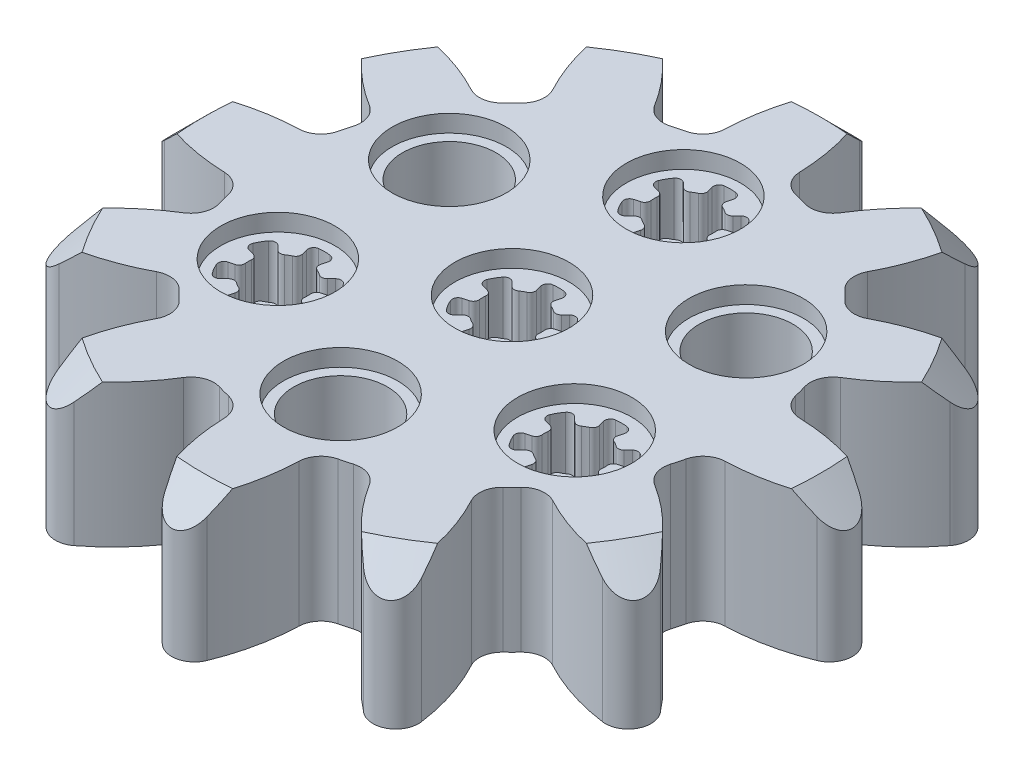
from build123d import *

# Parameters (mm, degrees)
SKETCH3_R           = 32
BOSS_EXTRUDE1_DEPTH = 12.5
CHAMFER1_SIZE       = 5
CUT_EXTRUDE3_DEPTH  = 47.949440891
SKETCH7_R           = 4.1
CUT_EXTRUDE4_DEPTH  = 47.949441054
SKETCH7_7_R         = 5
SKETCH7_7_R_2       = 4.1
CUT_EXTRUDE5_DEPTH  = 1.5
CUT_EXTRUDE8_DEPTH  = 9
SKETCH10_R          = 5
SKETCH10_R_2        = 4.1
BOSS_EXTRUDE2_DEPTH = 5
FILLET2_R           = 0.5
FILLET5_R           = 2
SKETCH8_R           = 1
CUT_EXTRUDE6_DEPTH  = 46.611126858


with BuildPart() as part:
    # Sketch3 → Boss-Extrude1 (new body)
    with BuildSketch(Plane(origin=(0, 0, 0), x_dir=(1, 0, 0), z_dir=(0, 1, 0))):
        with Locations(Location((0, 0, 0), (0, 0, 270))):
            Circle(SKETCH3_R)
    extrude(amount=BOSS_EXTRUDE1_DEPTH)

    # Chamfer1
    chamfer1_edges = [part.edges().sort_by_distance(p)[0] for p in [
        (0, 12.5, -32),
    ]]
    chamfer(chamfer1_edges, length=CHAMFER1_SIZE)

    # Sketch5 → Cut-Extrude3 (cut, through all)
    with BuildSketch(Plane(origin=(0, 12.5, 0), x_dir=(1, 0, 0), z_dir=(0, 1, 0))):
        with BuildLine():
            ThreePointArc((0.281278544, -31.998763763), (0.282056068, -31.998756919), (0.282833592, -31.998750056))
            ThreePointArc((0.282833592, -31.998750056), (8.418728035, -30.872722884), (16, -27.712812921))
            ThreePointArc((16, -27.712812921), (10.989548885, -24.179940154), (7.356424025, -19.241700173))
            ThreePointArc((7.356424025, -19.241700173), (5.331672329, -19.898072022), (3.25, -20.342013175))
            ThreePointArc((3.25, -20.342013175), (2.572741567, -26.435216878), (0, -32))
            ThreePointArc((0, -32), (0.14064063, -31.999690939), (0.281278544, -31.998763763))
        make_face()
        with BuildLine():
            ThreePointArc((12.98558915, -15.991700173), (15.445667993, -21.607198588), (16, -27.712812921))
            ThreePointArc((16, -27.712812921), (22.627416998, -22.627416998), (27.712812921, -16))
            ThreePointArc((27.712812921, -16), (21.607198588, -15.445667993), (15.991700173, -12.98558915))
            ThreePointArc((15.991700173, -12.98558915), (14.566399692, -14.566399692), (12.98558915, -15.991700173))
        make_face()
        with BuildLine():
            ThreePointArc((-16, -27.712812921), (-8.282209443, -30.909626441), (0, -32))
            ThreePointArc((0, -32), (-2.572741567, -26.435216878), (-3.25, -20.342013175))
            ThreePointArc((-3.25, -20.342013175), (-5.331672329, -19.898072022), (-7.356424025, -19.241700173))
            ThreePointArc((-7.356424025, -19.241700173), (-10.989548885, -24.179940154), (-16, -27.712812921))
        make_face()
        with BuildLine():
            ThreePointArc((19.241700173, -7.356424025), (24.179940154, -10.989548885), (27.712812921, -16))
            ThreePointArc((27.712812921, -16), (30.909626441, -8.282209443), (32, 0))
            ThreePointArc((32, 0), (26.435216878, -2.572741567), (20.342013175, -3.25))
            ThreePointArc((20.342013175, -3.25), (19.898072022, -5.331672329), (19.241700173, -7.356424025))
        make_face()
        with BuildLine():
            ThreePointArc((-27.712812921, -16), (-22.627416998, -22.627416998), (-16, -27.712812921))
            ThreePointArc((-16, -27.712812921), (-15.445667993, -21.607198588), (-12.98558915, -15.991700173))
            ThreePointArc((-12.98558915, -15.991700173), (-14.566399692, -14.566399692), (-15.991700173, -12.98558915))
            ThreePointArc((-15.991700173, -12.98558915), (-21.607198588, -15.445667993), (-27.712812921, -16))
        make_face()
        with BuildLine():
            ThreePointArc((20.342013175, 3.25), (26.435216878, 2.572741567), (32, 0))
            ThreePointArc((32, 0), (30.909626441, 8.282209443), (27.712812921, 16))
            ThreePointArc((27.712812921, 16), (24.179940154, 10.989548885), (19.241700173, 7.356424025))
            ThreePointArc((19.241700173, 7.356424025), (19.898072022, 5.331672329), (20.342013175, 3.25))
        make_face()
        with BuildLine():
            ThreePointArc((-32, 0), (-30.909626441, -8.282209443), (-27.712812921, -16))
            ThreePointArc((-27.712812921, -16), (-24.179940154, -10.989548885), (-19.241700173, -7.356424025))
            ThreePointArc((-19.241700173, -7.356424025), (-19.898072022, -5.331672329), (-20.342013175, -3.25))
            ThreePointArc((-20.342013175, -3.25), (-26.435216878, -2.572741567), (-32, 0))
        make_face()
        with BuildLine():
            ThreePointArc((15.991700173, 12.98558915), (21.607198588, 15.445667993), (27.712812921, 16))
            ThreePointArc((27.712812921, 16), (22.627416998, 22.627416998), (16, 27.712812921))
            ThreePointArc((16, 27.712812921), (15.445667993, 21.607198588), (12.98558915, 15.991700173))
            ThreePointArc((12.98558915, 15.991700173), (14.566399692, 14.566399692), (15.991700173, 12.98558915))
        make_face()
        with BuildLine():
            ThreePointArc((-27.712812921, 16), (-30.909626441, 8.282209443), (-32, 0))
            ThreePointArc((-32, 0), (-26.435216878, 2.572741567), (-20.342013175, 3.25))
            ThreePointArc((-20.342013175, 3.25), (-19.898072022, 5.331672329), (-19.241700173, 7.356424025))
            ThreePointArc((-19.241700173, 7.356424025), (-24.179940154, 10.989548885), (-27.712812921, 16))
        make_face()
        with BuildLine():
            ThreePointArc((7.356424025, 19.241700173), (10.989548885, 24.179940154), (16, 27.712812921))
            ThreePointArc((16, 27.712812921), (8.282209443, 30.909626441), (0, 32))
            ThreePointArc((0, 32), (2.572741567, 26.435216878), (3.25, 20.342013175))
            ThreePointArc((3.25, 20.342013175), (5.331672329, 19.898072022), (7.356424025, 19.241700173))
        make_face()
        with BuildLine():
            ThreePointArc((-16, 27.712812921), (-22.627416998, 22.627416998), (-27.712812921, 16))
            ThreePointArc((-27.712812921, 16), (-21.607198588, 15.445667993), (-15.991700173, 12.98558915))
            ThreePointArc((-15.991700173, 12.98558915), (-14.566399692, 14.566399692), (-12.98558915, 15.991700173))
            ThreePointArc((-12.98558915, 15.991700173), (-15.445667993, 21.607198588), (-16, 27.712812921))
        make_face()
        with BuildLine():
            ThreePointArc((-3.25, 20.342013175), (-2.572741567, 26.435216878), (0, 32))
            ThreePointArc((0, 32), (-8.282209443, 30.909626441), (-16, 27.712812921))
            ThreePointArc((-16, 27.712812921), (-10.989548885, 24.179940154), (-7.356424025, 19.241700173))
            ThreePointArc((-7.356424025, 19.241700173), (-5.331672329, 19.898072022), (-3.25, 20.342013175))
        make_face()
    extrude(amount=-CUT_EXTRUDE3_DEPTH, mode=Mode.SUBTRACT)

    # Sketch7 → Cut-Extrude4 (cut, through all)
    with BuildSketch(Plane(origin=(0, 12.5, 0), x_dir=(1, 0, 0), z_dir=(0, 1, 0))):
        with BuildLine():
            ThreePointArc((1.838477631, 16.838477631), (1.3, 17.25166605), (0.672929517, 17.511407148))
            Line((0.672929517, 17.511407148), (1.061158085, 18.960295888))
            ThreePointArc((1.061158085, 18.960295888), (0, 19.1), (-1.061158085, 18.960295888))
            Line((-1.061158085, 18.960295888), (-0.672929517, 17.511407148))
            ThreePointArc((-0.672929517, 17.511407148), (-1.3, 17.25166605), (-1.838477631, 16.838477631))
            Line((-1.838477631, 16.838477631), (-2.899137803, 17.899137803))
            ThreePointArc((-2.899137803, 17.899137803), (-3.550704156, 17.05), (-3.960295888, 16.061158085))
            Line((-3.960295888, 16.061158085), (-2.511407148, 15.672929517))
            ThreePointArc((-2.511407148, 15.672929517), (-2.6, 15), (-2.511407148, 14.327070483))
            Line((-2.511407148, 14.327070483), (-3.960295888, 13.938841915))
            ThreePointArc((-3.960295888, 13.938841915), (-3.550704156, 12.95), (-2.899137803, 12.100862197))
            Line((-2.899137803, 12.100862197), (-1.838477631, 13.161522369))
            ThreePointArc((-1.838477631, 13.161522369), (-1.3, 12.74833395), (-0.672929517, 12.488592852))
            Line((-0.672929517, 12.488592852), (-1.061158085, 11.039704112))
            ThreePointArc((-1.061158085, 11.039704112), (0, 10.9), (1.061158085, 11.039704112))
            Line((1.061158085, 11.039704112), (0.672929517, 12.488592852))
            ThreePointArc((0.672929517, 12.488592852), (1.3, 12.74833395), (1.838477631, 13.161522369))
            Line((1.838477631, 13.161522369), (2.899137803, 12.100862197))
            ThreePointArc((2.899137803, 12.100862197), (3.550704156, 12.95), (3.960295888, 13.938841915))
            Line((3.960295888, 13.938841915), (2.511407148, 14.327070483))
            ThreePointArc((2.511407148, 14.327070483), (2.6, 15), (2.511407148, 15.672929517))
            Line((2.511407148, 15.672929517), (3.960295888, 16.061158085))
            ThreePointArc((3.960295888, 16.061158085), (3.550704156, 17.05), (2.899137803, 17.899137803))
            Line((2.899137803, 17.899137803), (1.838477631, 16.838477631))
        make_face()
        with Locations(Location((12.990381057, 7.5, 0), (0, 0, 270))):
            Circle(SKETCH7_R)
        with BuildLine():
            Line((1.061158085, -3.960295888), (0.672929517, -2.511407148))
            ThreePointArc((0.672929517, -2.511407148), (1.3, -2.25166605), (1.838477631, -1.838477631))
            Line((1.838477631, -1.838477631), (2.899137803, -2.899137803))
            ThreePointArc((2.899137803, -2.899137803), (3.550704156, -2.05), (3.960295888, -1.061158085))
            Line((3.960295888, -1.061158085), (2.511407148, -0.672929517))
            ThreePointArc((2.511407148, -0.672929517), (2.6, 0), (2.511407148, 0.672929517))
            Line((2.511407148, 0.672929517), (3.960295888, 1.061158085))
            ThreePointArc((3.960295888, 1.061158085), (3.550704156, 2.05), (2.899137803, 2.899137803))
            Line((2.899137803, 2.899137803), (1.838477631, 1.838477631))
            ThreePointArc((1.838477631, 1.838477631), (1.3, 2.25166605), (0.672929517, 2.511407148))
            Line((0.672929517, 2.511407148), (1.061158085, 3.960295888))
            ThreePointArc((1.061158085, 3.960295888), (0, 4.1), (-1.061158085, 3.960295888))
            Line((-1.061158085, 3.960295888), (-0.672929517, 2.511407148))
            ThreePointArc((-0.672929517, 2.511407148), (-1.3, 2.25166605), (-1.838477631, 1.838477631))
            Line((-1.838477631, 1.838477631), (-2.899137803, 2.899137803))
            ThreePointArc((-2.899137803, 2.899137803), (-3.550704156, 2.05), (-3.960295888, 1.061158085))
            Line((-3.960295888, 1.061158085), (-2.511407148, 0.672929517))
            ThreePointArc((-2.511407148, 0.672929517), (-2.6, 0), (-2.511407148, -0.672929517))
            Line((-2.511407148, -0.672929517), (-3.960295888, -1.061158085))
            ThreePointArc((-3.960295888, -1.061158085), (-3.550704156, -2.05), (-2.899137803, -2.899137803))
            Line((-2.899137803, -2.899137803), (-1.838477631, -1.838477631))
            ThreePointArc((-1.838477631, -1.838477631), (-1.3, -2.25166605), (-0.672929517, -2.511407148))
            Line((-0.672929517, -2.511407148), (-1.061158085, -3.960295888))
            ThreePointArc((-1.061158085, -3.960295888), (0, -4.1), (1.061158085, -3.960295888))
        make_face()
        with Locations(Location((-12.990381057, 7.5, 0), (0, 0, 270))):
            Circle(SKETCH7_R)
        with BuildLine():
            ThreePointArc((-14.828858688, -9.338477631), (-14.290381057, -9.75166605), (-13.663310574, -10.011407148))
            Line((-13.663310574, -10.011407148), (-14.051539142, -11.460295888))
            ThreePointArc((-14.051539142, -11.460295888), (-12.990381057, -11.6), (-11.929222972, -11.460295888))
            Line((-11.929222972, -11.460295888), (-12.317451539, -10.011407148))
            ThreePointArc((-12.317451539, -10.011407148), (-11.690381057, -9.75166605), (-11.151903426, -9.338477631))
            Line((-11.151903426, -9.338477631), (-10.091243254, -10.399137803))
            ThreePointArc((-10.091243254, -10.399137803), (-9.439676901, -9.55), (-9.030085169, -8.561158085))
            Line((-9.030085169, -8.561158085), (-10.478973908, -8.172929517))
            ThreePointArc((-10.478973908, -8.172929517), (-10.390381057, -7.5), (-10.478973908, -6.827070483))
            Line((-10.478973908, -6.827070483), (-9.030085169, -6.438841915))
            ThreePointArc((-9.030085169, -6.438841915), (-9.439676901, -5.45), (-10.091243254, -4.600862197))
            Line((-10.091243254, -4.600862197), (-11.151903426, -5.661522369))
            ThreePointArc((-11.151903426, -5.661522369), (-11.690381057, -5.24833395), (-12.317451539, -4.988592852))
            Line((-12.317451539, -4.988592852), (-11.929222972, -3.539704112))
            ThreePointArc((-11.929222972, -3.539704112), (-12.990381057, -3.4), (-14.051539142, -3.539704112))
            Line((-14.051539142, -3.539704112), (-13.663310574, -4.988592852))
            ThreePointArc((-13.663310574, -4.988592852), (-14.290381057, -5.24833395), (-14.828858688, -5.661522369))
            Line((-14.828858688, -5.661522369), (-15.88951886, -4.600862197))
            ThreePointArc((-15.88951886, -4.600862197), (-16.541085212, -5.45), (-16.950676945, -6.438841915))
            Line((-16.950676945, -6.438841915), (-15.501788205, -6.827070483))
            ThreePointArc((-15.501788205, -6.827070483), (-15.590381057, -7.5), (-15.501788205, -8.172929517))
            Line((-15.501788205, -8.172929517), (-16.950676945, -8.561158085))
            ThreePointArc((-16.950676945, -8.561158085), (-16.541085212, -9.55), (-15.88951886, -10.399137803))
            Line((-15.88951886, -10.399137803), (-14.828858688, -9.338477631))
        make_face()
        with Locations(Location((0, -15, 0), (0, 0, 270))):
            Circle(SKETCH7_R)
        with BuildLine():
            ThreePointArc((15.501788205, -8.172929517), (15.590381057, -7.5), (15.501788205, -6.827070483))
            Line((15.501788205, -6.827070483), (16.950676945, -6.438841915))
            ThreePointArc((16.950676945, -6.438841915), (16.541085212, -5.45), (15.88951886, -4.600862197))
            Line((15.88951886, -4.600862197), (14.828858688, -5.661522369))
            ThreePointArc((14.828858688, -5.661522369), (14.290381057, -5.24833395), (13.663310574, -4.988592852))
            Line((13.663310574, -4.988592852), (14.051539142, -3.539704112))
            ThreePointArc((14.051539142, -3.539704112), (12.990381057, -3.4), (11.929222972, -3.539704112))
            Line((11.929222972, -3.539704112), (12.31745154, -4.988592852))
            ThreePointArc((12.31745154, -4.988592852), (11.690381057, -5.24833395), (11.151903426, -5.661522369))
            Line((11.151903426, -5.661522369), (10.091243254, -4.600862197))
            ThreePointArc((10.091243254, -4.600862197), (9.439676901, -5.45), (9.030085169, -6.438841915))
            Line((9.030085169, -6.438841915), (10.478973908, -6.827070483))
            ThreePointArc((10.478973908, -6.827070483), (10.390381057, -7.5), (10.478973908, -8.172929517))
            Line((10.478973908, -8.172929517), (9.030085169, -8.561158085))
            ThreePointArc((9.030085169, -8.561158085), (9.439676901, -9.55), (10.091243254, -10.399137803))
            Line((10.091243254, -10.399137803), (11.151903426, -9.338477631))
            ThreePointArc((11.151903426, -9.338477631), (11.690381057, -9.75166605), (12.31745154, -10.011407148))
            Line((12.31745154, -10.011407148), (11.929222972, -11.460295888))
            ThreePointArc((11.929222972, -11.460295888), (12.990381057, -11.6), (14.051539142, -11.460295888))
            Line((14.051539142, -11.460295888), (13.663310574, -10.011407148))
            ThreePointArc((13.663310574, -10.011407148), (14.290381057, -9.75166605), (14.828858688, -9.338477631))
            Line((14.828858688, -9.338477631), (15.88951886, -10.399137803))
            ThreePointArc((15.88951886, -10.399137803), (16.541085212, -9.55), (16.950676945, -8.561158085))
            Line((16.950676945, -8.561158085), (15.501788205, -8.172929517))
        make_face()
    extrude(amount=-CUT_EXTRUDE4_DEPTH, mode=Mode.SUBTRACT)

    # Sketch7_7 → Cut-Extrude5 (cut)
    with BuildSketch(Plane(origin=(0, 12.5, 0), x_dir=(1, 0, 0), z_dir=(0, 1, 0))):
        with Locations(Location((-12.990381057, 7.5, 0), (0, 0, 270))):
            Circle(SKETCH7_7_R)
        with Locations(Location((-12.990381057, 7.5, 0), (0, 0, 270))):
            Circle(SKETCH7_7_R_2, mode=Mode.SUBTRACT)
        with Locations(Location((12.990381057, 7.5, 0), (0, 0, 270))):
            Circle(SKETCH7_7_R)
        with Locations(Location((12.990381057, 7.5, 0), (0, 0, 270))):
            Circle(SKETCH7_7_R_2, mode=Mode.SUBTRACT)
        with Locations(Location((0, 15, 0), (0, 0, 270))):
            Circle(SKETCH7_7_R)
        with Locations((0, 15)):
            Circle(SKETCH7_7_R_2, mode=Mode.SUBTRACT)
        with BuildLine():
            Line((-2.511407148, 15.672929517), (-3.960295888, 16.061158085))
            ThreePointArc((-3.960295888, 16.061158085), (-4.1, 15), (-3.960295888, 13.938841915))
            Line((-3.960295888, 13.938841915), (-2.511407148, 14.327070483))
            ThreePointArc((-2.511407148, 14.327070483), (-2.6, 15), (-2.511407148, 15.672929517))
        make_face()
        with BuildLine():
            Line((-1.838477631, 13.161522369), (-2.899137803, 12.100862197))
            ThreePointArc((-2.899137803, 12.100862197), (-2.05, 11.449295844), (-1.061158085, 11.039704112))
            Line((-1.061158085, 11.039704112), (-0.672929517, 12.488592852))
            ThreePointArc((-0.672929517, 12.488592852), (-1.3, 12.74833395), (-1.838477631, 13.161522369))
        make_face()
        with BuildLine():
            ThreePointArc((1.061158085, 11.039704112), (2.05, 11.449295844), (2.899137803, 12.100862197))
            Line((2.899137803, 12.100862197), (1.838477631, 13.161522369))
            ThreePointArc((1.838477631, 13.161522369), (1.3, 12.74833395), (0.672929517, 12.488592852))
            Line((0.672929517, 12.488592852), (1.061158085, 11.039704112))
        make_face()
        with BuildLine():
            ThreePointArc((4.1, 15), (4.064923932, 15.535157388), (3.960295888, 16.061158085))
            Line((3.960295888, 16.061158085), (2.511407148, 15.672929517))
            ThreePointArc((2.511407148, 15.672929517), (2.6, 15), (2.511407148, 14.327070483))
            Line((2.511407148, 14.327070483), (3.960295888, 13.938841915))
            ThreePointArc((3.960295888, 13.938841915), (4.064923932, 14.464842612), (4.1, 15))
        make_face()
        with BuildLine():
            Line((1.061158085, 18.960295888), (0.672929517, 17.511407148))
            ThreePointArc((0.672929517, 17.511407148), (1.3, 17.25166605), (1.838477631, 16.838477631))
            Line((1.838477631, 16.838477631), (2.899137803, 17.899137803))
            ThreePointArc((2.899137803, 17.899137803), (2.05, 18.550704156), (1.061158085, 18.960295888))
        make_face()
        with BuildLine():
            Line((-0.672929517, 17.511407148), (-1.061158085, 18.960295888))
            ThreePointArc((-1.061158085, 18.960295888), (-2.05, 18.550704156), (-2.899137803, 17.899137803))
            Line((-2.899137803, 17.899137803), (-1.838477631, 16.838477631))
            ThreePointArc((-1.838477631, 16.838477631), (-1.3, 17.25166605), (-0.672929517, 17.511407148))
        make_face()
        with Locations(Location((0, 0, 0), (0, 0, 270))):
            Circle(SKETCH7_7_R)
        Circle(SKETCH7_7_R_2, mode=Mode.SUBTRACT)
        with Locations(Location((-12.990381057, -7.5, 0), (0, 0, 270))):
            Circle(SKETCH7_7_R)
        with Locations((-12.990381057, -7.5)):
            Circle(SKETCH7_7_R_2, mode=Mode.SUBTRACT)
        with BuildLine():
            ThreePointArc((-16.950676945, -6.438841915), (-17.090381057, -7.5), (-16.950676945, -8.561158085))
            Line((-16.950676945, -8.561158085), (-15.501788205, -8.172929517))
            ThreePointArc((-15.501788205, -8.172929517), (-15.590381057, -7.5), (-15.501788205, -6.827070483))
            Line((-15.501788205, -6.827070483), (-16.950676945, -6.438841915))
        make_face()
        with BuildLine():
            Line((2.511407148, -0.672929517), (3.960295888, -1.061158085))
            ThreePointArc((3.960295888, -1.061158085), (4.064923932, -0.535157388), (4.1, 0))
            ThreePointArc((4.1, 0), (4.064923932, 0.535157388), (3.960295888, 1.061158085))
            Line((3.960295888, 1.061158085), (2.511407148, 0.672929517))
            ThreePointArc((2.511407148, 0.672929517), (2.6, 0), (2.511407148, -0.672929517))
        make_face()
        with BuildLine():
            Line((1.838477631, 1.838477631), (2.899137803, 2.899137803))
            ThreePointArc((2.899137803, 2.899137803), (2.05, 3.550704156), (1.061158085, 3.960295888))
            Line((1.061158085, 3.960295888), (0.672929517, 2.511407148))
            ThreePointArc((0.672929517, 2.511407148), (1.3, 2.25166605), (1.838477631, 1.838477631))
        make_face()
        with BuildLine():
            ThreePointArc((-1.061158085, 3.960295888), (-2.05, 3.550704156), (-2.899137803, 2.899137803))
            Line((-2.899137803, 2.899137803), (-1.838477631, 1.838477631))
            ThreePointArc((-1.838477631, 1.838477631), (-1.3, 2.25166605), (-0.672929517, 2.511407148))
            Line((-0.672929517, 2.511407148), (-1.061158085, 3.960295888))
        make_face()
        with BuildLine():
            ThreePointArc((-3.960295888, 1.061158085), (-4.1, 0), (-3.960295888, -1.061158085))
            Line((-3.960295888, -1.061158085), (-2.511407148, -0.672929517))
            ThreePointArc((-2.511407148, -0.672929517), (-2.6, 0), (-2.511407148, 0.672929517))
            Line((-2.511407148, 0.672929517), (-3.960295888, 1.061158085))
        make_face()
        with BuildLine():
            ThreePointArc((-2.899137803, -2.899137803), (-2.05, -3.550704156), (-1.061158085, -3.960295888))
            Line((-1.061158085, -3.960295888), (-0.672929517, -2.511407148))
            ThreePointArc((-0.672929517, -2.511407148), (-1.3, -2.25166605), (-1.838477631, -1.838477631))
            Line((-1.838477631, -1.838477631), (-2.899137803, -2.899137803))
        make_face()
        with BuildLine():
            ThreePointArc((1.838477631, -1.838477631), (1.3, -2.25166605), (0.672929517, -2.511407148))
            Line((0.672929517, -2.511407148), (1.061158085, -3.960295888))
            ThreePointArc((1.061158085, -3.960295888), (2.05, -3.550704156), (2.899137803, -2.899137803))
            Line((2.899137803, -2.899137803), (1.838477631, -1.838477631))
        make_face()
        with Locations(Location((12.990381057, -7.5, 0), (0, 0, 270))):
            Circle(SKETCH7_7_R)
        with Locations((12.990381057, -7.5)):
            Circle(SKETCH7_7_R_2, mode=Mode.SUBTRACT)
        with BuildLine():
            Line((10.478973908, -6.827070483), (9.030085169, -6.438841915))
            ThreePointArc((9.030085169, -6.438841915), (8.890381057, -7.5), (9.030085169, -8.561158085))
            Line((9.030085169, -8.561158085), (10.478973908, -8.172929517))
            ThreePointArc((10.478973908, -8.172929517), (10.390381057, -7.5), (10.478973908, -6.827070483))
        make_face()
        with BuildLine():
            ThreePointArc((10.091243254, -10.399137803), (10.940381057, -11.050704156), (11.929222972, -11.460295888))
            Line((11.929222972, -11.460295888), (12.31745154, -10.011407148))
            ThreePointArc((12.31745154, -10.011407148), (11.690381057, -9.75166605), (11.151903426, -9.338477631))
            Line((11.151903426, -9.338477631), (10.091243254, -10.399137803))
        make_face()
        with BuildLine():
            ThreePointArc((14.051539142, -11.460295888), (15.040381057, -11.050704156), (15.88951886, -10.399137803))
            Line((15.88951886, -10.399137803), (14.828858688, -9.338477631))
            ThreePointArc((14.828858688, -9.338477631), (14.290381057, -9.75166605), (13.663310574, -10.011407148))
            Line((13.663310574, -10.011407148), (14.051539142, -11.460295888))
        make_face()
        with BuildLine():
            Line((16.950676945, -6.438841915), (15.501788205, -6.827070483))
            ThreePointArc((15.501788205, -6.827070483), (15.590381057, -7.5), (15.501788205, -8.172929517))
            Line((15.501788205, -8.172929517), (16.950676945, -8.561158085))
            ThreePointArc((16.950676945, -8.561158085), (17.055304988, -8.035157388), (17.090381057, -7.5))
            ThreePointArc((17.090381057, -7.5), (17.055304988, -6.964842612), (16.950676945, -6.438841915))
        make_face()
        with BuildLine():
            Line((14.828858688, -5.661522369), (15.88951886, -4.600862197))
            ThreePointArc((15.88951886, -4.600862197), (15.040381057, -3.949295844), (14.051539142, -3.539704112))
            Line((14.051539142, -3.539704112), (13.663310574, -4.988592852))
            ThreePointArc((13.663310574, -4.988592852), (14.290381057, -5.24833395), (14.828858688, -5.661522369))
        make_face()
        with BuildLine():
            Line((12.31745154, -4.988592852), (11.929222972, -3.539704112))
            ThreePointArc((11.929222972, -3.539704112), (10.940381057, -3.949295844), (10.091243254, -4.600862197))
            Line((10.091243254, -4.600862197), (11.151903426, -5.661522369))
            ThreePointArc((11.151903426, -5.661522369), (11.690381057, -5.24833395), (12.31745154, -4.988592852))
        make_face()
        with Locations(Location((0, -15, 0), (0, 0, 270))):
            Circle(SKETCH7_7_R)
        with Locations(Location((0, -15, 0), (0, 0, 270))):
            Circle(SKETCH7_7_R_2, mode=Mode.SUBTRACT)
        with BuildLine():
            Line((-10.478973908, -8.172929517), (-9.030085169, -8.561158085))
            ThreePointArc((-9.030085169, -8.561158085), (-8.925457125, -8.035157388), (-8.890381057, -7.5))
            ThreePointArc((-8.890381057, -7.5), (-8.925457125, -6.964842612), (-9.030085169, -6.438841915))
            Line((-9.030085169, -6.438841915), (-10.478973908, -6.827070483))
            ThreePointArc((-10.478973908, -6.827070483), (-10.390381057, -7.5), (-10.478973908, -8.172929517))
        make_face()
        with BuildLine():
            ThreePointArc((-10.091243254, -4.600862197), (-10.940381057, -3.949295844), (-11.929222972, -3.539704112))
            Line((-11.929222972, -3.539704112), (-12.317451539, -4.988592852))
            ThreePointArc((-12.317451539, -4.988592852), (-11.690381057, -5.24833395), (-11.151903426, -5.661522369))
            Line((-11.151903426, -5.661522369), (-10.091243254, -4.600862197))
        make_face()
        with BuildLine():
            ThreePointArc((-14.051539142, -3.539704112), (-15.040381057, -3.949295844), (-15.88951886, -4.600862197))
            Line((-15.88951886, -4.600862197), (-14.828858688, -5.661522369))
            ThreePointArc((-14.828858688, -5.661522369), (-14.290381057, -5.24833395), (-13.663310574, -4.988592852))
            Line((-13.663310574, -4.988592852), (-14.051539142, -3.539704112))
        make_face()
        with BuildLine():
            Line((-14.051539142, -11.460295888), (-13.663310574, -10.011407148))
            ThreePointArc((-13.663310574, -10.011407148), (-14.290381057, -9.75166605), (-14.828858688, -9.338477631))
            Line((-14.828858688, -9.338477631), (-15.88951886, -10.399137803))
            ThreePointArc((-15.88951886, -10.399137803), (-15.040381057, -11.050704156), (-14.051539142, -11.460295888))
        make_face()
        with BuildLine():
            Line((-12.317451539, -10.011407148), (-11.929222972, -11.460295888))
            ThreePointArc((-11.929222972, -11.460295888), (-10.940381057, -11.050704156), (-10.091243254, -10.399137803))
            Line((-10.091243254, -10.399137803), (-11.151903426, -9.338477631))
            ThreePointArc((-11.151903426, -9.338477631), (-11.690381057, -9.75166605), (-12.317451539, -10.011407148))
        make_face()
    extrude(amount=-CUT_EXTRUDE5_DEPTH, mode=Mode.SUBTRACT)

    # Sketch9 → Cut-Extrude8 (cut)
    with BuildSketch(Plane.XZ):
        with BuildLine():
            ThreePointArc((19.823990382, 3.319548968), (19.415109108, 5.202262807), (18.827853759, 7.037181455))
            ThreePointArc((18.827853759, 7.037181455), (18.817583954, 7.708585602), (19.234296537, 8.235121091))
            ThreePointArc((19.234296537, 8.235121091), (22.356445085, 10.568508745), (25.050681295, 13.385173573))
            ThreePointArc((25.050681295, 13.385173573), (25.139314849, 14.514190195), (24.117240996, 15.001939597))
            ThreePointArc((24.117240996, 15.001939597), (20.330819596, 14.076995009), (16.748972336, 12.539828879))
            ThreePointArc((16.748972336, 12.539828879), (16.084622936, 12.442212941), (15.508304791, 12.786808926))
            ThreePointArc((15.508304791, 12.786808926), (14.212846302, 14.212846302), (12.786808926, 15.508304791))
            ThreePointArc((12.786808926, 15.508304791), (12.442212941, 16.084622936), (12.539828879, 16.748972336))
            ThreePointArc((12.539828879, 16.748972336), (14.076995009, 20.330819596), (15.001939597, 24.117240996))
            ThreePointArc((15.001939597, 24.117240996), (14.514190195, 25.139314849), (13.385173573, 25.050681295))
            ThreePointArc((13.385173573, 25.050681295), (10.568508745, 22.356445085), (8.235121091, 19.234296537))
            ThreePointArc((8.235121091, 19.234296537), (7.708585602, 18.817583954), (7.037181455, 18.827853759))
            ThreePointArc((7.037181455, 18.827853759), (5.202262807, 19.415109108), (3.319548968, 19.823990382))
            ThreePointArc((3.319548968, 19.823990382), (2.732961018, 20.150798543), (2.485324201, 20.77494997))
            ThreePointArc((2.485324201, 20.77494997), (2.025625489, 24.645503755), (0.9334403, 28.38711317))
            ThreePointArc((0.9334403, 28.38711317), (0, 29.028380391), (-0.9334403, 28.38711317))
            ThreePointArc((-0.9334403, 28.38711317), (-2.025625489, 24.645503755), (-2.485324201, 20.77494997))
            ThreePointArc((-2.485324201, 20.77494997), (-2.732961018, 20.150798543), (-3.319548968, 19.823990382))
            ThreePointArc((-3.319548968, 19.823990382), (-5.202262807, 19.415109108), (-7.037181455, 18.827853759))
            ThreePointArc((-7.037181455, 18.827853759), (-7.708585602, 18.817583954), (-8.235121091, 19.234296537))
            ThreePointArc((-8.235121091, 19.234296537), (-10.568508745, 22.356445085), (-13.385173573, 25.050681295))
            ThreePointArc((-13.385173573, 25.050681295), (-14.514190195, 25.139314849), (-15.001939597, 24.117240996))
            ThreePointArc((-15.001939597, 24.117240996), (-14.076995009, 20.330819596), (-12.539828879, 16.748972336))
            ThreePointArc((-12.539828879, 16.748972336), (-12.442212941, 16.084622936), (-12.786808926, 15.508304791))
            ThreePointArc((-12.786808926, 15.508304791), (-14.212846302, 14.212846302), (-15.508304791, 12.786808926))
            ThreePointArc((-15.508304791, 12.786808926), (-16.084622936, 12.442212941), (-16.748972336, 12.539828879))
            ThreePointArc((-16.748972336, 12.539828879), (-20.330819596, 14.076995009), (-24.117240996, 15.001939597))
            ThreePointArc((-24.117240996, 15.001939597), (-25.139314849, 14.514190195), (-25.050681295, 13.385173573))
            ThreePointArc((-25.050681295, 13.385173573), (-22.356445085, 10.568508745), (-19.234296537, 8.235121091))
            ThreePointArc((-19.234296537, 8.235121091), (-18.817583954, 7.708585602), (-18.827853759, 7.037181455))
            ThreePointArc((-18.827853759, 7.037181455), (-19.415109108, 5.202262807), (-19.823990382, 3.319548968))
            ThreePointArc((-19.823990382, 3.319548968), (-20.150798543, 2.732961018), (-20.77494997, 2.485324201))
            ThreePointArc((-20.77494997, 2.485324201), (-24.645503755, 2.025625489), (-28.38711317, 0.9334403))
            ThreePointArc((-28.38711317, 0.9334403), (-29.028380391, 0), (-28.38711317, -0.9334403))
            ThreePointArc((-28.38711317, -0.9334403), (-24.645503755, -2.025625489), (-20.77494997, -2.485324201))
            ThreePointArc((-20.77494997, -2.485324201), (-20.150798543, -2.732961018), (-19.823990382, -3.319548968))
            ThreePointArc((-19.823990382, -3.319548968), (-19.415109108, -5.202262807), (-18.827853759, -7.037181455))
            ThreePointArc((-18.827853759, -7.037181455), (-18.817583954, -7.708585602), (-19.234296537, -8.235121091))
            ThreePointArc((-19.234296537, -8.235121091), (-22.356445085, -10.568508745), (-25.050681295, -13.385173573))
            ThreePointArc((-25.050681295, -13.385173573), (-25.139314849, -14.514190195), (-24.117240996, -15.001939597))
            ThreePointArc((-24.117240996, -15.001939597), (-20.330819596, -14.076995009), (-16.748972336, -12.539828879))
            ThreePointArc((-16.748972336, -12.539828879), (-16.084622936, -12.442212941), (-15.508304791, -12.786808926))
            ThreePointArc((-15.508304791, -12.786808926), (-14.212846302, -14.212846302), (-12.786808926, -15.508304791))
            ThreePointArc((-12.786808926, -15.508304791), (-12.442212941, -16.084622936), (-12.539828879, -16.748972336))
            ThreePointArc((-12.539828879, -16.748972336), (-14.076995009, -20.330819596), (-15.001939597, -24.117240996))
            ThreePointArc((-15.001939597, -24.117240996), (-14.514190195, -25.139314849), (-13.385173573, -25.050681295))
            ThreePointArc((-13.385173573, -25.050681295), (-10.568508745, -22.356445085), (-8.235121091, -19.234296537))
            ThreePointArc((-8.235121091, -19.234296537), (-7.708585602, -18.817583954), (-7.037181455, -18.827853759))
            ThreePointArc((-7.037181455, -18.827853759), (-5.202262807, -19.415109108), (-3.319548968, -19.823990382))
            ThreePointArc((-3.319548968, -19.823990382), (-2.732961018, -20.150798543), (-2.485324201, -20.77494997))
            ThreePointArc((-2.485324201, -20.77494997), (-2.025625489, -24.645503755), (-0.9334403, -28.38711317))
            ThreePointArc((-0.9334403, -28.38711317), (0, -29.028380391), (0.9334403, -28.38711317))
            ThreePointArc((0.9334403, -28.38711317), (2.025625489, -24.645503755), (2.485324201, -20.77494997))
            ThreePointArc((2.485324201, -20.77494997), (2.732961018, -20.150798543), (3.319548968, -19.823990382))
            ThreePointArc((3.319548968, -19.823990382), (5.202262807, -19.415109108), (7.037181455, -18.827853759))
            ThreePointArc((7.037181455, -18.827853759), (7.708585602, -18.817583954), (8.235121091, -19.234296537))
            ThreePointArc((8.235121091, -19.234296537), (10.568508745, -22.356445085), (13.385173573, -25.050681295))
            ThreePointArc((13.385173573, -25.050681295), (14.514190195, -25.139314849), (15.001939597, -24.117240996))
            ThreePointArc((15.001939597, -24.117240996), (14.076995009, -20.330819596), (12.539828879, -16.748972336))
            ThreePointArc((12.539828879, -16.748972336), (12.442212941, -16.084622936), (12.786808926, -15.508304791))
            ThreePointArc((12.786808926, -15.508304791), (14.212846302, -14.212846302), (15.508304791, -12.786808926))
            ThreePointArc((15.508304791, -12.786808926), (16.084622936, -12.442212941), (16.748972336, -12.539828879))
            ThreePointArc((16.748972336, -12.539828879), (20.330819596, -14.076995009), (24.117240996, -15.001939597))
            ThreePointArc((24.117240996, -15.001939597), (25.139314849, -14.514190195), (25.050681295, -13.385173573))
            ThreePointArc((25.050681295, -13.385173573), (22.356445085, -10.568508745), (19.234296537, -8.235121091))
            ThreePointArc((19.234296537, -8.235121091), (18.817583954, -7.708585602), (18.827853759, -7.037181455))
            ThreePointArc((18.827853759, -7.037181455), (19.415109108, -5.202262807), (19.823990382, -3.319548968))
            ThreePointArc((19.823990382, -3.319548968), (20.150798543, -2.732961018), (20.77494997, -2.485324201))
            ThreePointArc((20.77494997, -2.485324201), (24.645503755, -2.025625489), (28.38711317, -0.9334403))
            ThreePointArc((28.38711317, -0.9334403), (29.028380391, 0), (28.38711317, 0.9334403))
            ThreePointArc((28.38711317, 0.9334403), (24.645503755, 2.025625489), (20.77494997, 2.485324201))
            ThreePointArc((20.77494997, 2.485324201), (20.150798543, 2.732961018), (19.823990382, 3.319548968))
        make_face()
        with BuildLine():
            Line((4.637481778, 13.130839024), (9.052899278, 10.581596542))
            ThreePointArc((9.052899278, 10.581596542), (17.320508076, 10), (13.690381057, 2.549242482))
            Line((13.690381057, 2.549242482), (13.690381057, -2.549242482))
            ThreePointArc((13.690381057, -2.549242482), (17.320508076, -10), (9.052899278, -10.581596542))
            Line((9.052899278, -10.581596542), (4.637481778, -13.130839024))
            ThreePointArc((4.637481778, -13.130839024), (0, -20), (-4.637481778, -13.130839024))
            Line((-4.637481778, -13.130839024), (-9.052899278, -10.581596542))
            ThreePointArc((-9.052899278, -10.581596542), (-17.320508076, -10), (-13.690381057, -2.549242482))
            Line((-13.690381057, -2.549242482), (-13.690381057, 2.549242482))
            ThreePointArc((-13.690381057, 2.549242482), (-17.320508076, 10), (-9.052899278, 10.581596542))
            Line((-9.052899278, 10.581596542), (-4.637481778, 13.130839024))
            ThreePointArc((-4.637481778, 13.130839024), (0, 20), (4.637481778, 13.130839024))
        make_face(mode=Mode.SUBTRACT)
        with BuildLine():
            Line((-0.7, -10.049242482), (-0.7, -4.950757518))
            ThreePointArc((-0.7, -4.950757518), (-2.5, -4.330127019), (-3.937481778, -3.081596542))
            Line((-3.937481778, -3.081596542), (-8.352899278, -5.630839024))
            ThreePointArc((-8.352899278, -5.630839024), (-7.990381057, -7.5), (-8.352899278, -9.369160976))
            Line((-8.352899278, -9.369160976), (-3.937481778, -11.918403458))
            ThreePointArc((-3.937481778, -11.918403458), (-2.5, -10.669872981), (-0.7, -10.049242482))
        make_face()
        with BuildLine():
            ThreePointArc((-4.637481778, -1.869160976), (-5, 0), (-4.637481778, 1.869160976))
            Line((-4.637481778, 1.869160976), (-9.052899278, 4.418403458))
            ThreePointArc((-9.052899278, 4.418403458), (-10.490381057, 3.169872981), (-12.290381057, 2.549242482))
            Line((-12.290381057, 2.549242482), (-12.290381057, -2.549242482))
            ThreePointArc((-12.290381057, -2.549242482), (-10.490381057, -3.169872981), (-9.052899278, -4.418403458))
            Line((-9.052899278, -4.418403458), (-4.637481778, -1.869160976))
        make_face()
        with BuildLine():
            Line((8.352899278, -5.630839024), (3.937481778, -3.081596542))
            ThreePointArc((3.937481778, -3.081596542), (2.5, -4.330127019), (0.7, -4.950757518))
            Line((0.7, -4.950757518), (0.7, -10.049242482))
            ThreePointArc((0.7, -10.049242482), (2.5, -10.669872981), (3.937481778, -11.918403458))
            Line((3.937481778, -11.918403458), (8.352899278, -9.369160976))
            ThreePointArc((8.352899278, -9.369160976), (7.990381057, -7.5), (8.352899278, -5.630839024))
        make_face()
        with BuildLine():
            ThreePointArc((-3.937481778, 3.081596542), (-2.5, 4.330127019), (-0.7, 4.950757518))
            Line((-0.7, 4.950757518), (-0.7, 10.049242482))
            ThreePointArc((-0.7, 10.049242482), (-2.5, 10.669872981), (-3.937481778, 11.918403458))
            Line((-3.937481778, 11.918403458), (-8.352899278, 9.369160976))
            ThreePointArc((-8.352899278, 9.369160976), (-7.990381057, 7.5), (-8.352899278, 5.630839024))
            Line((-8.352899278, 5.630839024), (-3.937481778, 3.081596542))
        make_face()
        with BuildLine():
            Line((9.052899278, 4.418403458), (4.637481778, 1.869160976))
            ThreePointArc((4.637481778, 1.869160976), (5, 0), (4.637481778, -1.869160976))
            Line((4.637481778, -1.869160976), (9.052899278, -4.418403458))
            ThreePointArc((9.052899278, -4.418403458), (10.490381057, -3.169872981), (12.290381057, -2.549242482))
            Line((12.290381057, -2.549242482), (12.290381057, 2.549242482))
            ThreePointArc((12.290381057, 2.549242482), (10.490381057, 3.169872981), (9.052899278, 4.418403458))
        make_face()
        with BuildLine():
            ThreePointArc((0.7, 4.950757518), (2.5, 4.330127019), (3.937481778, 3.081596542))
            Line((3.937481778, 3.081596542), (8.352899278, 5.630839024))
            ThreePointArc((8.352899278, 5.630839024), (7.990381057, 7.5), (8.352899278, 9.369160976))
            Line((8.352899278, 9.369160976), (3.937481778, 11.918403458))
            ThreePointArc((3.937481778, 11.918403458), (2.5, 10.669872981), (0.7, 10.049242482))
            Line((0.7, 10.049242482), (0.7, 4.950757518))
        make_face()
    extrude(amount=-CUT_EXTRUDE8_DEPTH, mode=Mode.SUBTRACT)

    # Sketch10 → Boss-Extrude2 (add)
    with BuildSketch(Plane.XZ):
        with Locations(Location((0, 0, 0), (0, 0, 90))):
            Circle(SKETCH10_R)
        Circle(SKETCH10_R_2, mode=Mode.SUBTRACT)
        with BuildLine():
            Line((1.061158085, 3.960295888), (0.672929517, 2.511407148))
            ThreePointArc((0.672929517, 2.511407148), (1.3, 2.25166605), (1.838477631, 1.838477631))
            Line((1.838477631, 1.838477631), (2.899137803, 2.899137803))
            ThreePointArc((2.899137803, 2.899137803), (2.05, 3.550704156), (1.061158085, 3.960295888))
        make_face()
        with BuildLine():
            ThreePointArc((-1.838477631, 1.838477631), (-1.3, 2.25166605), (-0.672929517, 2.511407148))
            Line((-0.672929517, 2.511407148), (-1.061158085, 3.960295888))
            ThreePointArc((-1.061158085, 3.960295888), (-2.05, 3.550704156), (-2.899137803, 2.899137803))
            Line((-2.899137803, 2.899137803), (-1.838477631, 1.838477631))
        make_face()
        with BuildLine():
            ThreePointArc((-2.511407148, -0.672929517), (-2.6, 0), (-2.511407148, 0.672929517))
            Line((-2.511407148, 0.672929517), (-3.960295888, 1.061158085))
            ThreePointArc((-3.960295888, 1.061158085), (-4.1, 0), (-3.960295888, -1.061158085))
            Line((-3.960295888, -1.061158085), (-2.511407148, -0.672929517))
        make_face()
        with BuildLine():
            ThreePointArc((-0.672929517, -2.511407148), (-1.3, -2.25166605), (-1.838477631, -1.838477631))
            Line((-1.838477631, -1.838477631), (-2.899137803, -2.899137803))
            ThreePointArc((-2.899137803, -2.899137803), (-2.05, -3.550704156), (-1.061158085, -3.960295888))
            Line((-1.061158085, -3.960295888), (-0.672929517, -2.511407148))
        make_face()
        with BuildLine():
            Line((2.899137803, -2.899137803), (1.838477631, -1.838477631))
            ThreePointArc((1.838477631, -1.838477631), (1.3, -2.25166605), (0.672929517, -2.511407148))
            Line((0.672929517, -2.511407148), (1.061158085, -3.960295888))
            ThreePointArc((1.061158085, -3.960295888), (2.05, -3.550704156), (2.899137803, -2.899137803))
        make_face()
        with BuildLine():
            Line((3.960295888, 1.061158085), (2.511407148, 0.672929517))
            ThreePointArc((2.511407148, 0.672929517), (2.57775664, 0.3393681), (2.6, 0))
            ThreePointArc((2.6, 0), (2.57775664, -0.3393681), (2.511407148, -0.672929517))
            Line((2.511407148, -0.672929517), (3.960295888, -1.061158085))
            ThreePointArc((3.960295888, -1.061158085), (4.064923932, -0.535157388), (4.1, 0))
            ThreePointArc((4.1, 0), (4.064923932, 0.535157388), (3.960295888, 1.061158085))
        make_face()
    extrude(amount=BOSS_EXTRUDE2_DEPTH)

    # Fillet2
    fillet2_edges = [part.edges().sort_by_distance(p)[0] for p in [
        (-0.672929517, 5.5, 2.511407148),
        (-1.838477631, 5.5, 1.838477631),
        (-2.899137803, 5.5, 2.899137803),
        (-3.960295888, 5.5, 1.061158085),
        (-2.511407148, 5.5, 0.672929517),
        (-2.511407148, 5.5, -0.672929517),
        (-3.960295888, 5.5, -1.061158085),
        (-2.899137803, 5.5, -2.899137803),
        (-1.838477631, 5.5, -1.838477631),
        (-0.672929517, 5.5, -2.511407148),
        (-1.061158085, 5.5, -3.960295888),
        (1.061158085, 5.5, -3.960295888),
        (0.672929517, 5.5, -2.511407148),
        (1.838477631, 5.5, -1.838477631),
        (2.899137803, 5.5, -2.899137803),
        (3.960295888, 5.5, -1.061158085),
        (2.511407148, 5.5, -0.672929517),
        (2.511407148, 5.5, 0.672929517),
        (3.960295888, 5.5, 1.061158085),
        (2.899137803, 5.5, 2.899137803),
        (1.838477631, 5.5, 1.838477631),
        (0.672929517, 5.5, 2.511407148),
        (1.061158085, 5.5, 3.960295888),
        (-1.061158085, 5.5, 3.960295888),
        (-10.478973908, 5.5, 8.172929517),
        (-9.030085169, 5.5, 8.561158085),
        (-10.091243254, 5.5, 10.399137803),
        (-11.151903426, 5.5, 9.338477631),
        (-12.317451539, 5.5, 10.011407148),
        (-11.929222972, 5.5, 11.460295888),
        (-14.051539142, 5.5, 11.460295888),
        (-13.663310574, 5.5, 10.011407148),
        (-14.828858688, 5.5, 9.338477631),
        (-15.88951886, 5.5, 10.399137803),
        (-16.950676945, 5.5, 8.561158085),
        (-15.501788205, 5.5, 8.172929517),
        (-15.501788205, 5.5, 6.827070483),
        (-16.950676945, 5.5, 6.438841915),
        (-15.88951886, 5.5, 4.600862197),
        (-14.828858688, 5.5, 5.661522369),
        (-13.663310574, 5.5, 4.988592852),
        (-14.051539142, 5.5, 3.539704112),
        (-11.929222972, 5.5, 3.539704112),
        (-12.317451539, 5.5, 4.988592852),
        (-11.151903426, 5.5, 5.661522369),
        (-10.091243254, 5.5, 4.600862197),
        (-9.030085169, 5.5, 6.438841915),
        (-10.478973908, 5.5, 6.827070483),
        (12.31745154, 5.5, 4.988592852),
        (11.929222972, 5.5, 3.539704112),
        (14.051539142, 5.5, 3.539704112),
        (13.663310574, 5.5, 4.988592852),
        (14.828858688, 5.5, 5.661522369),
        (15.88951886, 5.5, 4.600862197),
        (16.950676945, 5.5, 6.438841915),
        (15.501788205, 5.5, 6.827070483),
        (15.501788205, 5.5, 8.172929517),
        (16.950676945, 5.5, 8.561158085),
        (15.88951886, 5.5, 10.399137803),
        (14.828858688, 5.5, 9.338477631),
        (13.663310574, 5.5, 10.011407148),
        (14.051539142, 5.5, 11.460295888),
        (11.929222972, 5.5, 11.460295888),
        (12.31745154, 5.5, 10.011407148),
        (11.151903426, 5.5, 9.338477631),
        (10.091243254, 5.5, 10.399137803),
        (9.030085169, 5.5, 8.561158085),
        (10.478973908, 5.5, 8.172929517),
        (10.478973908, 5.5, 6.827070483),
        (9.030085169, 5.5, 6.438841915),
        (10.091243254, 5.5, 4.600862197),
        (11.151903426, 5.5, 5.661522369),
        (2.511407148, 5.5, -14.327070483),
        (3.960295888, 5.5, -13.938841915),
        (2.899137803, 5.5, -12.100862197),
        (1.838477631, 5.5, -13.161522369),
        (0.672929517, 5.5, -12.488592852),
        (1.061158085, 5.5, -11.039704112),
        (-1.061158085, 5.5, -11.039704112),
        (-0.672929517, 5.5, -12.488592852),
        (-1.838477631, 5.5, -13.161522369),
        (-2.899137803, 5.5, -12.100862197),
        (-3.960295888, 5.5, -13.938841915),
        (-2.511407148, 5.5, -14.327070483),
        (-2.511407148, 5.5, -15.672929517),
        (-3.960295888, 5.5, -16.061158085),
        (-2.899137803, 5.5, -17.899137803),
        (-1.838477631, 5.5, -16.838477631),
        (-0.672929517, 5.5, -17.511407148),
        (-1.061158085, 5.5, -18.960295888),
        (1.061158085, 5.5, -18.960295888),
        (0.672929517, 5.5, -17.511407148),
        (1.838477631, 5.5, -16.838477631),
        (2.899137803, 5.5, -17.899137803),
        (3.960295888, 5.5, -16.061158085),
        (2.511407148, 5.5, -15.672929517),
    ]]
    fillet(fillet2_edges, radius=FILLET2_R)

    # Fillet5
    fillet5_edges = [part.edges().sort_by_distance(p)[0] for p in [
        (16, 3.75, -27.712812921),
        (7.356424025, 6.25, 19.241700173),
        (3.25, 6.25, 20.342013175),
        (12.98558915, 6.25, 15.991700173),
        (15.991700173, 6.25, 12.98558915),
        (19.241700173, 6.25, 7.356424025),
        (20.342013175, 6.25, 3.25),
        (20.342013175, 6.25, -3.25),
        (19.241700173, 6.25, -7.356424025),
        (12.98558915, 6.25, -15.991700173),
        (3.25, 6.25, -20.342013175),
        (15.991700173, 6.25, -12.98558915),
        (7.356424025, 6.25, -19.241700173),
        (-3.25, 6.25, -20.342013175),
        (-7.356424025, 6.25, -19.241700173),
        (-15.991700173, 6.25, -12.98558915),
        (-12.98558915, 6.25, -15.991700173),
        (-19.241700173, 6.25, -7.356424025),
        (-20.342013175, 6.25, -3.25),
        (-19.241700173, 6.25, 7.356424025),
        (-20.342013175, 6.25, 3.25),
        (-15.991700173, 6.25, 12.98558915),
        (-12.98558915, 6.25, 15.991700173),
        (-7.356424025, 6.25, 19.241700173),
        (-3.25, 6.25, 20.342013175),
        (27.712812921, 3.75, -16),
        (32, 3.75, 0),
        (27.712812921, 3.75, 16),
        (16, 3.75, 27.712812921),
        (0, 3.75, 32),
        (-27.712812921, 3.75, 16),
        (-16, 3.75, 27.712812921),
        (-32, 3.75, 0),
        (-27.712812921, 3.75, -16),
        (-16, 3.75, -27.712812921),
        (0, 3.75, -32),
    ]]
    fillet(fillet5_edges, radius=FILLET5_R)

    # Sketch8 → Cut-Extrude6 (cut, through all)
    with BuildSketch(Plane(origin=(0, 12.5, 0), x_dir=(1, 0, 0), z_dir=(0, 1, 0))):
        with Locations(Location((0, 28, 0), (0, 0, 269.99999996))):
            Circle(SKETCH8_R)
    extrude(amount=-CUT_EXTRUDE6_DEPTH, mode=Mode.SUBTRACT)


solid = part.part
